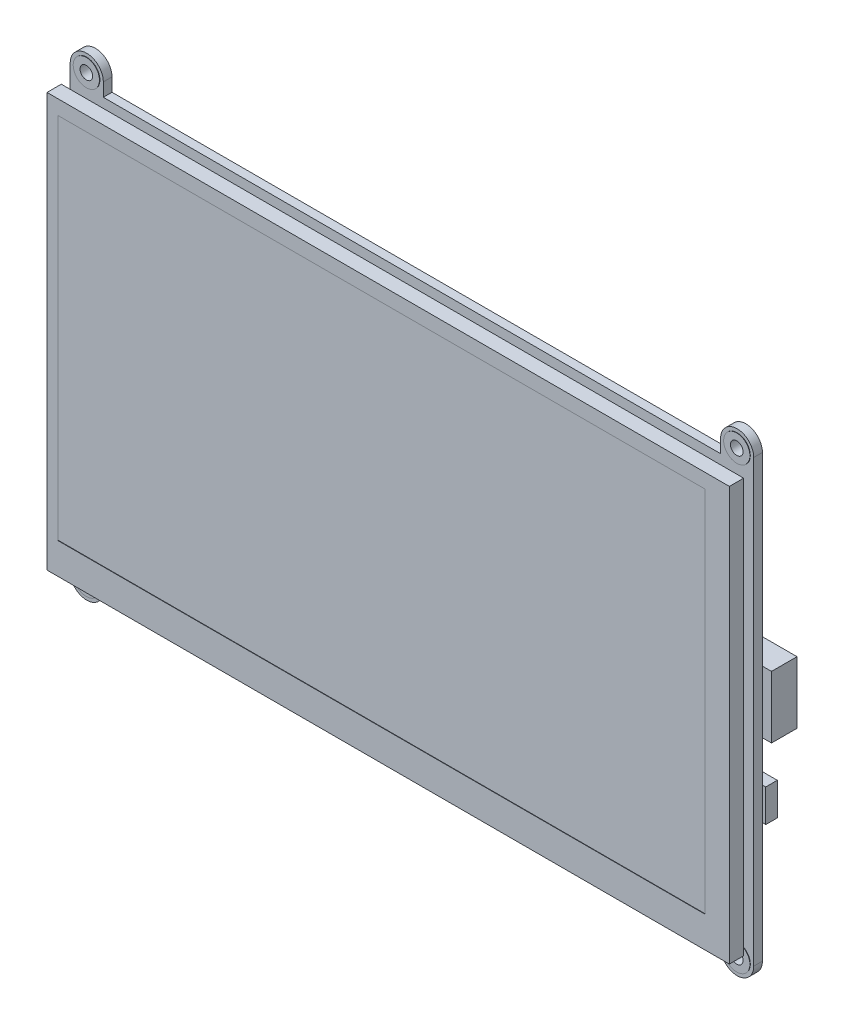
from build123d import *

# Parameters (mm, degrees)
ESQUISSE1_R             = 1.524
BOSS_EXTRU_1_DEPTH      = 2.1
ESQUISSE2_W             = 25.4
ESQUISSE2_H             = 25.4
BOSS_EXTRU_2_DEPTH      = 2.3
ESQUISSE3_W             = 164.95
ESQUISSE3_H             = 100
BOSS_EXTRU_3_DEPTH      = 3.45
ESQUISSE4_W             = 156.5
ESQUISSE4_H             = 89
ENL_V_MAT_EXTRU_1_DEPTH = 0.1
ESQUISSE5_W             = 29.8
ESQUISSE5_H             = 7.4
ENL_V_MAT_EXTRU_2_DEPTH = 2.1
CONG_1_R                = 1
ESQUISSE6_W             = 26.5
ESQUISSE6_H             = 5.4
BOSS_EXTRU_4_DEPTH      = 2
ESQUISSE7_W             = 11.59
ESQUISSE7_H             = 15
BOSS_EXTRU_5_DEPTH      = 6.16
ESQUISSE8_W             = 5.5
ESQUISSE8_H             = 7.88
BOSS_EXTRU_6_DEPTH      = 2.8
ESQUISSE9_W             = 13.84
ESQUISSE9_H             = 13.84
BOSS_EXTRU_7_DEPTH      = 1
ESQUISSE10_R            = 3.175
ESQUISSE10_R_2          = 1.524
BOSS_EXTRU_8_DEPTH      = 0.1
BOSS_EXTRU_8_DEPTH_BACK = 2.11


with BuildPart() as part:
    # Esquisse1 → Boss.-Extru.1 (new body)
    with BuildSketch(Plane.XY):
        with BuildLine():
            Line((-82.615, 53.25), (-82.615, -53.25))
            ThreePointArc((-82.615, -53.25), (-78.613, -57.252), (-74.611, -53.25))
            Line((-74.611, -53.25), (-74.611, -50.036793886))
            Line((-74.611, -50.036793886), (74.611, -50.036793886))
            Line((74.611, -50.036793886), (74.611, -53.25))
            ThreePointArc((74.611, -53.25), (78.613, -57.252), (82.615, -53.25))
            Line((82.615, -53.25), (82.615, 53.25))
            ThreePointArc((82.615, 53.25), (78.613, 57.252), (74.611, 53.25))
            Line((74.611, 53.25), (74.611, 50.036793886))
            Line((74.611, 50.036793886), (-74.611, 50.036793886))
            Line((-74.611, 50.036793886), (-74.611, 53.25))
            ThreePointArc((-74.611, 53.25), (-78.613, 57.252), (-82.615, 53.25))
        make_face()
        with Locations((-78.613, 53.25)):
            Circle(ESQUISSE1_R, mode=Mode.SUBTRACT)
        with Locations((-78.613, -53.25)):
            Circle(ESQUISSE1_R, mode=Mode.SUBTRACT)
        with Locations((78.613, -53.25)):
            Circle(ESQUISSE1_R, mode=Mode.SUBTRACT)
        with Locations((78.613, 53.25)):
            Circle(ESQUISSE1_R, mode=Mode.SUBTRACT)
    extrude(amount=BOSS_EXTRU_1_DEPTH)

    # Esquisse2 → Boss.-Extru.2 (add)
    with BuildSketch(Plane.XY.offset(2.1)):
        with Locations((-61.8, 27.3)):
            Rectangle(ESQUISSE2_W, ESQUISSE2_H)
        with Locations((-61.8, -27.3)):
            Rectangle(ESQUISSE2_W, ESQUISSE2_H)
        with Locations((61.8, 27.3)):
            Rectangle(ESQUISSE2_W, ESQUISSE2_H)
        with Locations((61.8, -27.3)):
            Rectangle(ESQUISSE2_W, ESQUISSE2_H)
    extrude(amount=BOSS_EXTRU_2_DEPTH)

    # Esquisse3 → Boss.-Extru.3 (add)
    with BuildSketch(Plane.XY.offset(4.4)):
        Rectangle(ESQUISSE3_W, ESQUISSE3_H)
    extrude(amount=BOSS_EXTRU_3_DEPTH)

    # Esquisse4 → Enlèv. mat.-Extru.1 (cut)
    with BuildSketch(Plane.XY.offset(7.85)):
        with Locations((-1.605, 2)):
            Rectangle(ESQUISSE4_W, ESQUISSE4_H)
    extrude(amount=-ENL_V_MAT_EXTRU_1_DEPTH, mode=Mode.SUBTRACT)

    # Esquisse5 → Enlèv. mat.-Extru.2 (cut)
    with BuildSketch(Plane(origin=(0, 0, 0), x_dir=(-1, 0, 0), z_dir=(0, 0, -1))):
        with Locations((38.315, -0.136793886)):
            Rectangle(ESQUISSE5_W, ESQUISSE5_H)
    extrude(amount=-ENL_V_MAT_EXTRU_2_DEPTH, mode=Mode.SUBTRACT)

    # Congé1
    cong_1_edges = [part.edges().sort_by_distance(p)[0] for p in [
        (-23.415, -3.836793886, 1.05),
        (-23.415, 3.563206114, 1.05),
        (-53.215, 3.563206114, 1.05),
        (-53.215, -3.836793886, 1.05),
    ]]
    fillet(cong_1_edges, radius=CONG_1_R)

    # Esquisse6 → Boss.-Extru.4 (add)
    with BuildSketch(Plane(origin=(0, 0, 0), x_dir=(-1, 0, 0), z_dir=(0, 0, -1))):
        with Locations((38.315, 6.363206114)):
            Rectangle(ESQUISSE6_W, ESQUISSE6_H)
    extrude(amount=BOSS_EXTRU_4_DEPTH)

    # Esquisse7 → Boss.-Extru.5 (add)
    with BuildSketch(Plane(origin=(0, 0, 0), x_dir=(-1, 0, 0), z_dir=(0, 0, -1))):
        with Locations((-79.02, 1.017206114)):
            Rectangle(ESQUISSE7_W, ESQUISSE7_H)
    extrude(amount=BOSS_EXTRU_5_DEPTH)

    # Esquisse8 → Boss.-Extru.6 (add)
    with BuildSketch(Plane(origin=(0, 0, 0), x_dir=(-1, 0, 0), z_dir=(0, 0, -1))):
        with Locations((-80.665, -20.318793886)):
            Rectangle(ESQUISSE8_W, ESQUISSE8_H)
    extrude(amount=BOSS_EXTRU_6_DEPTH)

    # Esquisse9 → Boss.-Extru.7 (add)
    with BuildSketch(Plane(origin=(0, 0, 0), x_dir=(-1, 0, 0), z_dir=(0, 0, -1))):
        with Locations((-52.695, 0.616793886)):
            Rectangle(ESQUISSE9_W, ESQUISSE9_H)
    extrude(amount=BOSS_EXTRU_7_DEPTH)

    # Esquisse10 → Boss.-Extru.8 (add, two sides)
    with BuildSketch(Plane.XY.offset(2.1)) as boss_extru_8_sk:
        with Locations((-78.613, 53.25)):
            Circle(ESQUISSE10_R)
        with Locations((-78.613, 53.25)):
            Circle(ESQUISSE10_R_2, mode=Mode.SUBTRACT)
        with Locations((-78.613, -53.25)):
            Circle(ESQUISSE10_R)
        with Locations((-78.613, -53.25)):
            Circle(ESQUISSE10_R_2, mode=Mode.SUBTRACT)
        with Locations((78.613, -53.25)):
            Circle(ESQUISSE10_R)
        with Locations((78.613, -53.25)):
            Circle(ESQUISSE10_R_2, mode=Mode.SUBTRACT)
        with Locations((78.613, 53.25)):
            Circle(ESQUISSE10_R)
        with Locations((78.613, 53.25)):
            Circle(ESQUISSE10_R_2, mode=Mode.SUBTRACT)
    extrude(amount=BOSS_EXTRU_8_DEPTH)
    extrude(boss_extru_8_sk.sketch, amount=-BOSS_EXTRU_8_DEPTH_BACK)


solid = part.part
